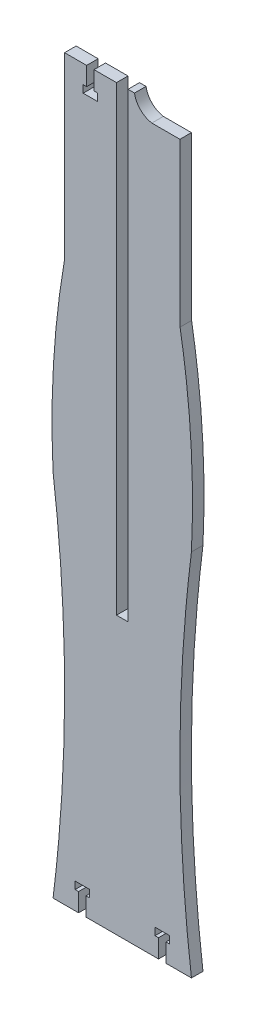
from build123d import *

# Parameters (mm, degrees)
BOSS_EXTRUDE1_DEPTH = 6.35


with BuildPart() as part:
    # Sketch2 → Boss-Extrude1 (new body)
    with BuildSketch(Plane.XY):
        with BuildLine():
            Line((-41.275, 0), (-27.223297828, 0))
            Line((-27.223297828, 0), (-27.223297828, 10.16))
            Line((-27.223297828, 10.16), (-29.128297828, 10.16))
            Line((-29.128297828, 10.16), (-29.128297828, 14.224))
            Line((-29.128297828, 14.224), (-21.254297828, 14.224))
            Line((-21.254297828, 14.224), (-21.254297828, 10.16))
            Line((-21.254297828, 10.16), (-23.159297828, 10.16))
            Line((-23.159297828, 10.16), (-23.159297828, 0))
            Line((-23.159297828, 0), (16.809297828, 0))
            Line((16.809297828, 0), (16.809297828, 10.16))
            Line((16.809297828, 10.16), (14.904297828, 10.16))
            Line((14.904297828, 10.16), (14.904297828, 14.224))
            Line((14.904297828, 14.224), (22.778297828, 14.224))
            Line((22.778297828, 14.224), (22.778297828, 10.16))
            Line((22.778297828, 10.16), (20.873297828, 10.16))
            Line((20.873297828, 10.16), (20.873297828, 0))
            Line((20.873297828, 0), (34.925, 0))
            add(Edge.make_bspline(
                [(34.925, 203.2), (22.225, 101.6), (34.925, 0)],
                knots=[0, 0, 0, 1, 1, 1], degree=2))
            add(Edge.make_bspline(
                [(28.665162854, 307.273451332), (37.499078487, 256.223776594), (34.925, 203.2)],
                knots=[0.49744374, 0.49744374, 0.49744374, 1, 1, 1], degree=2))
            Line((28.665162854, 307.273451332), (28.583690525, 396.845491603))
            Line((28.583690525, 396.845491603), (13.109843668, 396.845491603))
            ThreePointArc((13.109843668, 396.845491603), (6.812169641, 400.09411622), (3.579509775, 406.4))
            Line((3.579509775, 406.4), (0, 406.4))
            Line((0, 406.4), (0, 152.4))
            Line((0, 152.4), (-6.35, 152.4))
            Line((-6.35, 152.4), (-6.35, 406.4))
            Line((-6.35, 406.4), (-18.7325, 406.4))
            Line((-18.7325, 406.4), (-18.7325, 396.24))
            Line((-18.7325, 396.24), (-16.8275, 396.24))
            Line((-16.8275, 396.24), (-16.8275, 392.176))
            Line((-16.8275, 392.176), (-20.7645, 392.176))
            Line((-20.7645, 392.176), (-24.7015, 392.176))
            Line((-24.7015, 392.176), (-24.7015, 396.24))
            Line((-24.7015, 396.24), (-22.7965, 396.24))
            Line((-22.7965, 396.24), (-22.7965, 406.4))
            Line((-22.7965, 406.4), (-34.925, 406.4))
            Line((-34.925, 406.4), (-35.015162854, 307.273451332))
            add(Edge.make_bspline(
                [(-35.015162854, 307.273451332), (-43.849078487, 256.223776594), (-41.275, 203.2)],
                knots=[0.49744374, 0.49744374, 0.49744374, 1, 1, 1], degree=2))
            add(Edge.make_bspline(
                [(-41.275, 203.2), (-28.575, 101.6), (-41.275, 0)],
                knots=[0, 0, 0, 1, 1, 1], degree=2))
        make_face()
    extrude(amount=BOSS_EXTRUDE1_DEPTH)


solid = part.part
